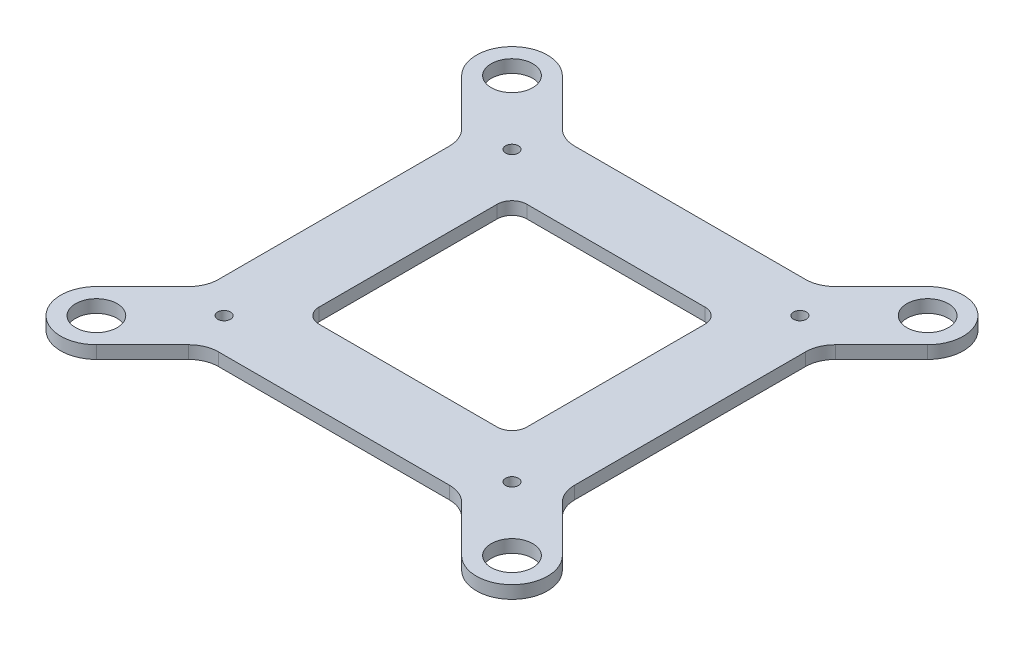
from build123d import *

# Parameters (mm, degrees)
SKETCH1_R           = 1.075
SKETCH1_R_2         = 3.5
BOSS_EXTRUDE1_DEPTH = 2.15
SKETCH2_R           = 1.075
BOSS_EXTRUDE2_DEPTH = 2.5


with BuildPart() as part:
    # Sketch1 → Boss-Extrude1 (new body)
    with BuildSketch(Plane(origin=(0, 0, 0), x_dir=(1, 0, 0), z_dir=(0, 1, 0))):
        with BuildLine():
            Line((-30, 19.443650814), (-30, -19.443650814))
            ThreePointArc((-30, -19.443650814), (-30.380602337, -21.357067976), (-31.464466094, -22.97918472))
            Line((-31.464466094, -22.97918472), (-39.242640687, -30.757359313))
            ThreePointArc((-39.242640687, -30.757359313), (-39.242640687, -39.242640687), (-30.757359313, -39.242640687))
            Line((-30.757359313, -39.242640687), (-22.97918472, -31.464466094))
            ThreePointArc((-22.97918472, -31.464466094), (-21.357067976, -30.380602337), (-19.443650814, -30))
            Line((-19.443650814, -30), (19.443650814, -30))
            ThreePointArc((19.443650814, -30), (21.357067976, -30.380602337), (22.97918472, -31.464466094))
            Line((22.97918472, -31.464466094), (30.757359313, -39.242640687))
            ThreePointArc((30.757359313, -39.242640687), (39.242640687, -39.242640687), (39.242640687, -30.757359313))
            Line((39.242640687, -30.757359313), (31.464466094, -22.97918472))
            ThreePointArc((31.464466094, -22.97918472), (30.380602337, -21.357067976), (30, -19.443650814))
            Line((30, -19.443650814), (30, 19.443650814))
            ThreePointArc((30, 19.443650814), (30.380602337, 21.357067976), (31.464466094, 22.97918472))
            Line((31.464466094, 22.97918472), (39.242640687, 30.757359313))
            ThreePointArc((39.242640687, 30.757359313), (39.242640687, 39.242640687), (30.757359313, 39.242640687))
            Line((30.757359313, 39.242640687), (22.97918472, 31.464466094))
            ThreePointArc((22.97918472, 31.464466094), (21.357067976, 30.380602337), (19.443650814, 30))
            Line((19.443650814, 30), (-19.443650814, 30))
            ThreePointArc((-19.443650814, 30), (-21.357067976, 30.380602337), (-22.97918472, 31.464466094))
            Line((-22.97918472, 31.464466094), (-30.757359313, 39.242640687))
            ThreePointArc((-30.757359313, 39.242640687), (-39.242640687, 39.242640687), (-39.242640687, 30.757359313))
            Line((-39.242640687, 30.757359313), (-31.464466094, 22.97918472))
            ThreePointArc((-31.464466094, 22.97918472), (-30.380602337, 21.357067976), (-30, 19.443650814))
        make_face()
        with Locations((-24.245, 24.245)):
            Circle(SKETCH1_R, mode=Mode.SUBTRACT)
        with Locations((24.245, 24.245)):
            Circle(SKETCH1_R, mode=Mode.SUBTRACT)
        with Locations((24.245, -24.245)):
            Circle(SKETCH1_R, mode=Mode.SUBTRACT)
        with Locations((-24.245, -24.245)):
            Circle(SKETCH1_R, mode=Mode.SUBTRACT)
        with Locations((35, -35)):
            Circle(SKETCH1_R_2, mode=Mode.SUBTRACT)
        with Locations((-35, -35)):
            Circle(SKETCH1_R_2, mode=Mode.SUBTRACT)
        with Locations((-35, 35)):
            Circle(SKETCH1_R_2, mode=Mode.SUBTRACT)
        with Locations((35, 35)):
            Circle(SKETCH1_R_2, mode=Mode.SUBTRACT)
        with BuildLine():
            Line((-15, -17.5), (15, -17.5))
            ThreePointArc((15, -17.5), (16.767766953, -16.767766953), (17.5, -15))
            Line((17.5, -15), (17.5, 15))
            ThreePointArc((17.5, 15), (16.767766953, 16.767766953), (15, 17.5))
            Line((15, 17.5), (-15, 17.5))
            ThreePointArc((-15, 17.5), (-16.767766953, 16.767766953), (-17.5, 15))
            Line((-17.5, 15), (-17.5, -15))
            ThreePointArc((-17.5, -15), (-16.767766953, -16.767766953), (-15, -17.5))
        make_face(mode=Mode.SUBTRACT)
    extrude(amount=BOSS_EXTRUDE1_DEPTH)

    # Sketch2 → Boss-Extrude2 (add)
    with BuildSketch(Plane.XZ):
        with BuildLine():
            Line((27.32, -24.245), (27.32, -14.245))
            ThreePointArc((27.32, -14.245), (24.245, -11.17), (21.17, -14.245))
            Line((21.17, -14.245), (21.17, -18.67))
            ThreePointArc((21.17, -18.67), (20.437766953, -20.437766953), (18.67, -21.17))
            Line((18.67, -21.17), (14.245, -21.17))
            ThreePointArc((14.245, -21.17), (11.17, -24.245), (14.245, -27.32))
            Line((14.245, -27.32), (24.245, -27.32))
            ThreePointArc((24.245, -27.32), (26.419353352, -26.419353352), (27.32, -24.245))
        make_face()
        with Locations((24.245, -24.245)):
            Circle(SKETCH2_R, mode=Mode.SUBTRACT)
        with BuildLine():
            Line((-24.245, -27.32), (-14.245, -27.32))
            ThreePointArc((-14.245, -27.32), (-11.17, -24.245), (-14.245, -21.17))
            Line((-14.245, -21.17), (-18.67, -21.17))
            ThreePointArc((-18.67, -21.17), (-20.437766953, -20.437766953), (-21.17, -18.67))
            Line((-21.17, -18.67), (-21.17, -14.245))
            ThreePointArc((-21.17, -14.245), (-24.245, -11.17), (-27.32, -14.245))
            Line((-27.32, -14.245), (-27.32, -24.245))
            ThreePointArc((-27.32, -24.245), (-26.419353352, -26.419353352), (-24.245, -27.32))
        make_face()
        with Locations((-24.245, -24.245)):
            Circle(SKETCH2_R, mode=Mode.SUBTRACT)
        with BuildLine():
            Line((-27.32, 24.245), (-27.32, 14.245))
            ThreePointArc((-27.32, 14.245), (-24.245, 11.17), (-21.17, 14.245))
            Line((-21.17, 14.245), (-21.17, 18.67))
            ThreePointArc((-21.17, 18.67), (-20.437766953, 20.437766953), (-18.67, 21.17))
            Line((-18.67, 21.17), (-14.245, 21.17))
            ThreePointArc((-14.245, 21.17), (-11.17, 24.245), (-14.245, 27.32))
            Line((-14.245, 27.32), (-24.245, 27.32))
            ThreePointArc((-24.245, 27.32), (-26.419353352, 26.419353352), (-27.32, 24.245))
        make_face()
        with Locations((-24.245, 24.245)):
            Circle(SKETCH2_R, mode=Mode.SUBTRACT)
        with BuildLine():
            Line((24.245, 27.32), (14.245, 27.32))
            ThreePointArc((14.245, 27.32), (11.17, 24.245), (14.245, 21.17))
            Line((14.245, 21.17), (18.67, 21.17))
            ThreePointArc((18.67, 21.17), (20.437766953, 20.437766953), (21.17, 18.67))
            Line((21.17, 18.67), (21.17, 14.245))
            ThreePointArc((21.17, 14.245), (24.245, 11.17), (27.32, 14.245))
            Line((27.32, 14.245), (27.32, 24.245))
            ThreePointArc((27.32, 24.245), (26.419353352, 26.419353352), (24.245, 27.32))
        make_face()
        with Locations((24.245, 24.245)):
            Circle(SKETCH2_R, mode=Mode.SUBTRACT)
    extrude(amount=BOSS_EXTRUDE2_DEPTH)


solid = part.part
